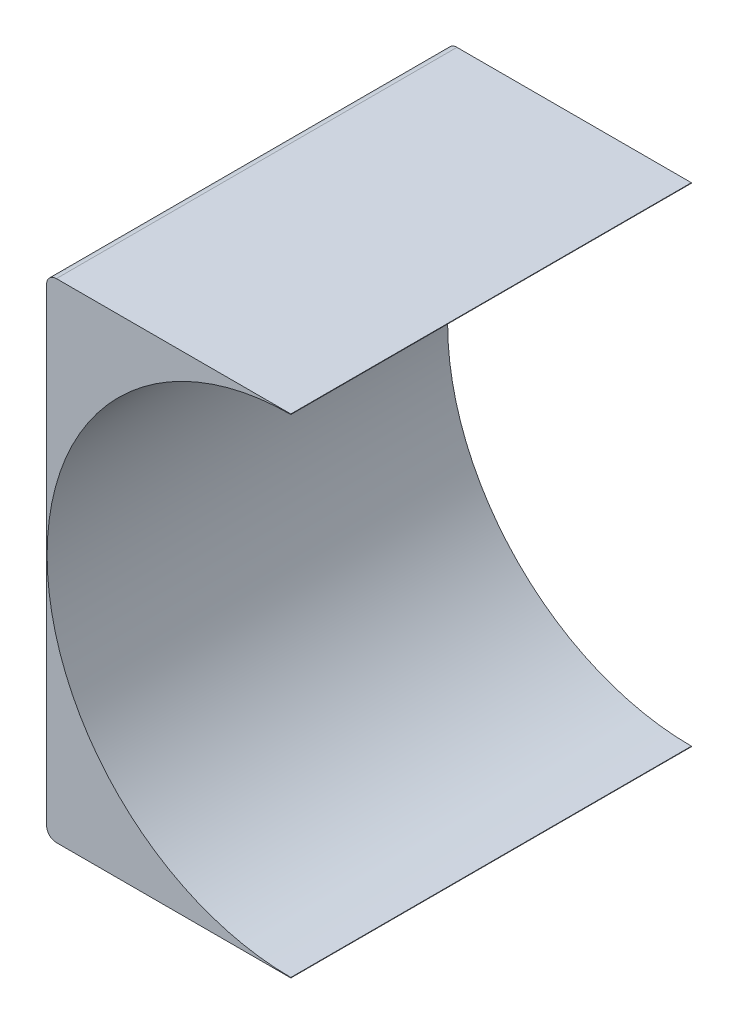
from build123d import *

# Parameters (mm, degrees)
SKETCH_1_W          = 25
SKETCH_1_H          = 41
EXTRUDE_1_DEPTH     = 50
FILLET_1_R          = 1
SKETCH_2_R          = 24.95
CUT_EXTRUDE_3_DEPTH = 41
FILLET_2_R          = 1


with BuildPart() as part:
    # Эскиз1 → Бобышка-Вытянуть1 (new body)
    with BuildSketch(Plane(origin=(0, 0, 0), x_dir=(1, 0, 0), z_dir=(0, 1, 0))):
        Rectangle(SKETCH_1_W, SKETCH_1_H)
    extrude(amount=EXTRUDE_1_DEPTH)

    # Скругление1
    fillet_1_edges = [part.edges().sort_by_distance(p)[0] for p in [
        (-12.5, 0, 0),
    ]]
    fillet(fillet_1_edges, radius=FILLET_1_R)

    # Эскиз2 → Вырез-Вытянуть3 (cut)
    with BuildSketch(Plane.XY.offset(20.5)):
        with Locations((12.5, 25)):
            Circle(SKETCH_2_R)
    extrude(amount=-CUT_EXTRUDE_3_DEPTH, mode=Mode.SUBTRACT)

    # Скругление2
    fillet_2_edges = [part.edges().sort_by_distance(p)[0] for p in [
        (-12.5, 50, 0),
    ]]
    fillet(fillet_2_edges, radius=FILLET_2_R)


solid = part.part
